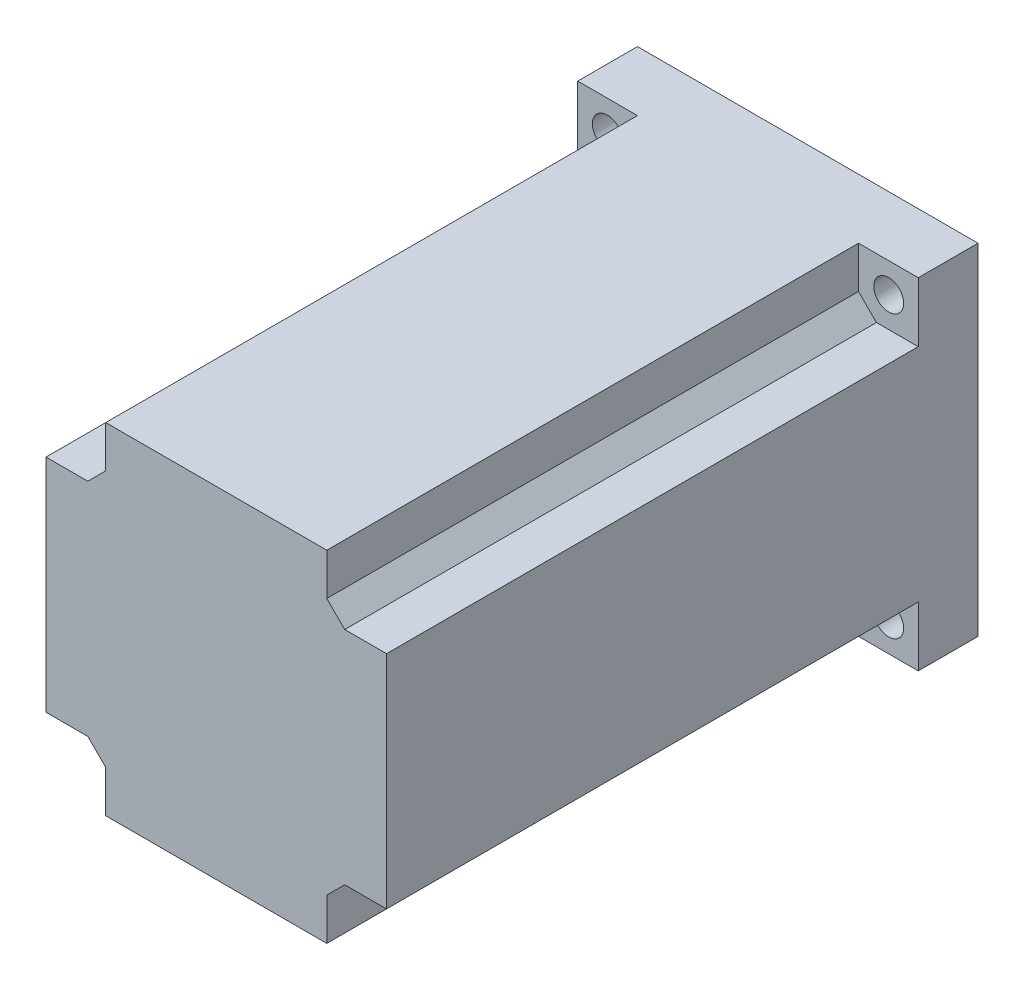
from build123d import *

# Parameters (mm, degrees)
SKETCH1_W           = 57
SKETCH1_H           = 57
SKETCH1_R           = 2.5
BOSS_EXTRUDE2_DEPTH = 99
SKETCH3_W           = 10
SKETCH3_H           = 10
CUT_EXTRUDE1_DEPTH  = 89
CHAMFER1_SIZE       = 3
SKETCH4_R           = 19.05
BOSS_EXTRUDE5_DEPTH = 1.6
SKETCH9_R           = 4.025639025
CUT_EXTRUDE3_DEPTH  = 1.6


with BuildPart() as part:
    # Sketch1 → Boss-Extrude2 (new body)
    with BuildSketch(Plane.XY):
        Rectangle(SKETCH1_W, SKETCH1_H)
        with Locations((23.55, -23.55)):
            Circle(SKETCH1_R, mode=Mode.SUBTRACT)
        with Locations((23.55, 23.55)):
            Circle(SKETCH1_R, mode=Mode.SUBTRACT)
        with Locations((-23.55, 23.55)):
            Circle(SKETCH1_R, mode=Mode.SUBTRACT)
        with Locations((-23.55, -23.55)):
            Circle(SKETCH1_R, mode=Mode.SUBTRACT)
    extrude(amount=BOSS_EXTRUDE2_DEPTH)

    # Sketch3 → Cut-Extrude1 (cut)
    with BuildSketch(Plane.XY.offset(99)):
        with Locations((-23.5, 23.5)):
            Rectangle(SKETCH3_W, SKETCH3_H)
        with Locations((-23.5, -23.5)):
            Rectangle(SKETCH3_W, SKETCH3_H)
        with Locations((23.5, -23.5)):
            Rectangle(SKETCH3_W, SKETCH3_H)
        with Locations((23.5, 23.5)):
            Rectangle(SKETCH3_W, SKETCH3_H)
    extrude(amount=-CUT_EXTRUDE1_DEPTH, mode=Mode.SUBTRACT)

    # Chamfer1
    chamfer1_edges = [part.edges().sort_by_distance(p)[0] for p in [
        (-18.5, -18.5, 54.5),
        (18.5, -18.5, 54.5),
        (18.5, 18.5, 54.5),
        (-18.5, 18.5, 54.5),
    ]]
    chamfer(chamfer1_edges, length=CHAMFER1_SIZE)

    # Sketch4 → Boss-Extrude5 (add)
    with BuildSketch(Plane(origin=(0, 0, 0), x_dir=(-1, 0, 0), z_dir=(0, 0, -1))):
        Circle(SKETCH4_R)
    extrude(amount=BOSS_EXTRUDE5_DEPTH)

    # Sketch9 → Cut-Extrude3 (cut)
    with BuildSketch(Plane(origin=(0, 0, -1.6), x_dir=(-1, 0, 0), z_dir=(0, 0, -1))):
        Circle(SKETCH9_R)
    extrude(amount=-CUT_EXTRUDE3_DEPTH, mode=Mode.SUBTRACT)


solid = part.part
